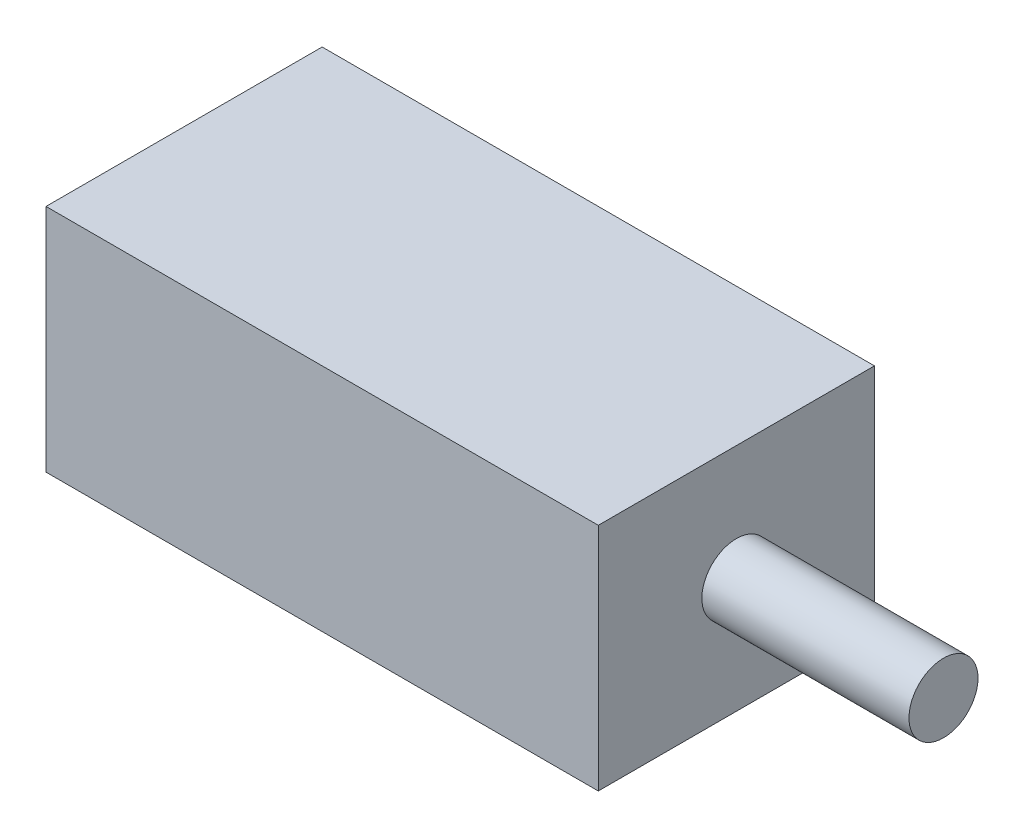
from build123d import *

# Parameters (mm, degrees)
SKETCH1_W           = 24
SKETCH1_H           = 10
BOSS_EXTRUDE1_DEPTH = 6
SKETCH2_R           = 1.5
BOSS_EXTRUDE2_DEPTH = 21


with BuildPart() as part:
    # Sketch1 → Boss-Extrude1 (new body, symmetric)
    with BuildSketch(Plane.XY):
        Rectangle(SKETCH1_W, SKETCH1_H)
    extrude(amount=BOSS_EXTRUDE1_DEPTH, both=True)

    # Sketch2 → Boss-Extrude2 (add)
    with BuildSketch(Plane(origin=(0, 0, 0), x_dir=(0, 0, -1), z_dir=(1, 0, 0))):
        Circle(SKETCH2_R)
    extrude(amount=BOSS_EXTRUDE2_DEPTH)


solid = part.part
